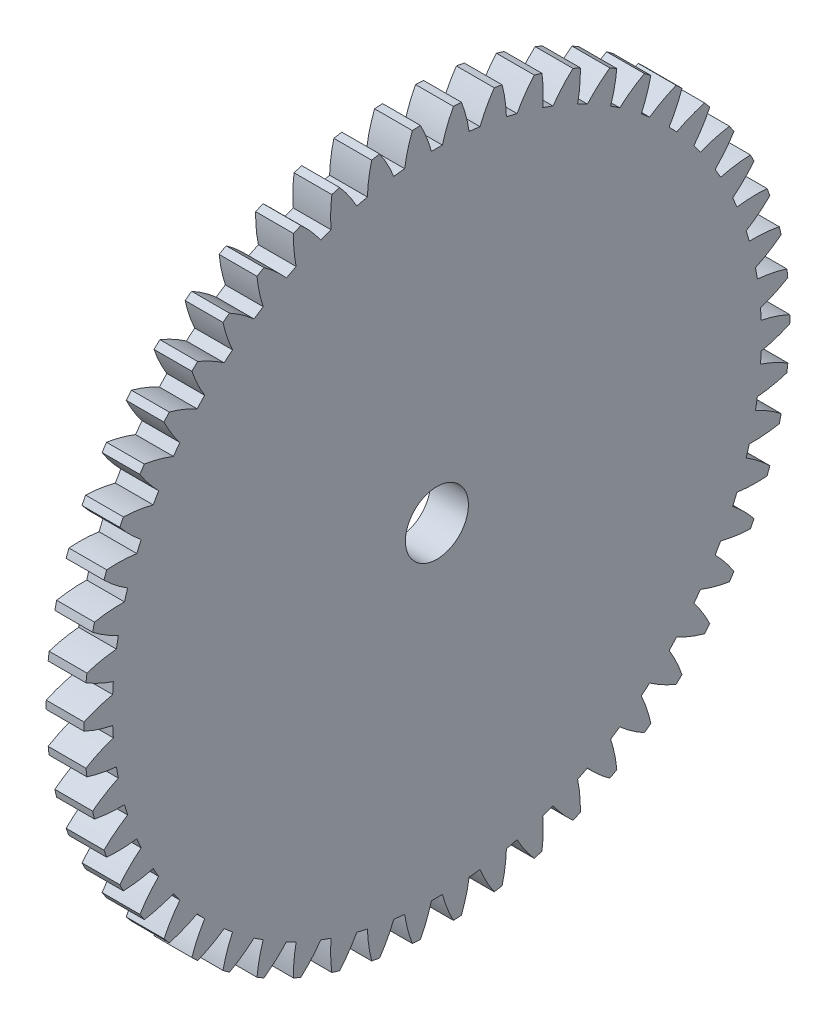
from build123d import *

# Parameters (mm, degrees)
BASPROSKE_W     = 3
BASPROSKE_H     = 28
TOOTHCUT_DEPTH  = 40.711459303
TEETHCUTS_COUNT = 54
TEETHCUTS_ANGLE = 353.333333333
BORSKE_R        = 2.5
BORE_DEPTH      = 50.0000508


with BuildPart() as part:
    # BasProSke → Base-Revolve (revolve)
    with BuildSketch(Plane(origin=(0, 0, 0), x_dir=(1, 0, 0), z_dir=(0, 1, 0)), mode=Mode.PRIVATE) as base_revolve_sk:
        with Locations((1.5, 14)):
            Rectangle(BASPROSKE_W, BASPROSKE_H)
    revolve(base_revolve_sk.sketch.rotate(Axis((-10, 0, 0), (1, 0, 0)), 180), axis=Axis((-10, 0, 0), (1, 0, 0)))

    # TooCutSke → ToothCut (cut, through all)
    with BuildSketch(Plane(origin=(0, 0, 0), x_dir=(0, 0, -1), z_dir=(1, 0, 0))):
        with BuildLine():
            ThreePointArc((0.434342569, 25.745336423), (0, 25.749), (-0.434342569, 25.745336423))
            ThreePointArc((-0.434342569, 25.745336423), (-0.815032242, 26.894686589), (-1.321977338, 27.994203348))
            ThreePointArc((-1.321977338, 27.994203348), (0, 28.0254), (1.321977338, 27.994203348))
            ThreePointArc((1.321977338, 27.994203348), (0.815032242, 26.894686589), (0.434342569, 25.745336423))
        make_face()
    toothcut = extrude(amount=TOOTHCUT_DEPTH, mode=Mode.SUBTRACT)

    # TeethCuts: ToothCut ×54 about axis
    teethcuts_axis = Axis((-10, 0, 0), (1, 0, 0))
    for i in range(1, TEETHCUTS_COUNT):
        add(toothcut.rotate(teethcuts_axis, i * TEETHCUTS_ANGLE / (TEETHCUTS_COUNT - 1)), mode=Mode.SUBTRACT)

    # BorSke → Bore (cut, symmetric)
    with BuildSketch(Plane(origin=(0, 0, 0), x_dir=(0, 0, -1), z_dir=(1, 0, 0))):
        with Locations(Location((0, 0, 0), (0, 0, 180))):
            Circle(BORSKE_R)
    extrude(amount=BORE_DEPTH, both=True, mode=Mode.SUBTRACT)


solid = part.part
